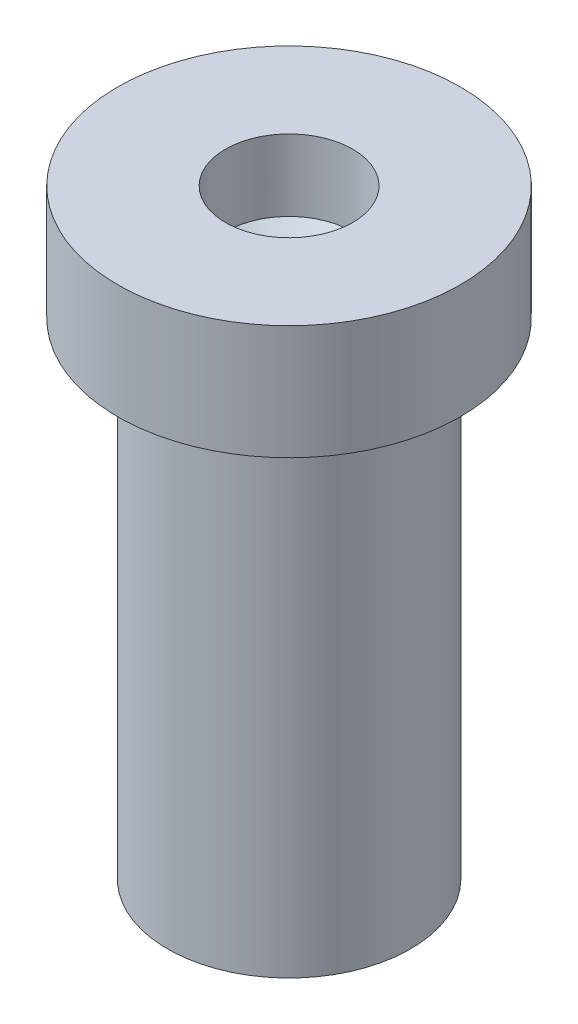
from build123d import *


with BuildPart() as part:
    # Sketch2 → Revolve1 (revolve)
    with BuildSketch(Plane.XY):
        Polygon((0, 0), (1.75, 0), (1.75, 7), (2.468651768, 7), (2.468651768, 8.647564862), (0.916559083, 8.647564862), (0.916559083, 7.617539717), (0, 7), align=None)
    revolve(axis=Axis((0, 0, 0), (0, 1, 0)))


solid = part.part
